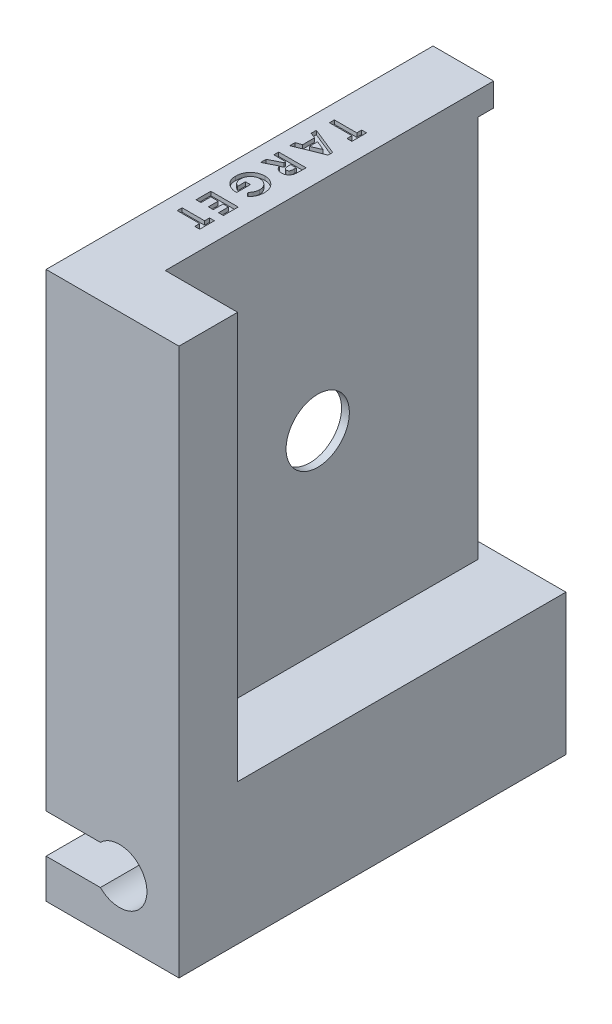
from build123d import *

# Parameters (mm, degrees)
ESQUISSE1_W              = 17
ESQUISSE1_H              = 85
BOSS_EXTRU_1_DEPTH       = 49.5
ESQUISSE2_W              = 1.8
ESQUISSE2_H              = 32.5
ENL_V_MAT_EXTRU_1_DEPTH  = 38.5
ESQUISSE3_W              = 17
ESQUISSE3_H              = 49
ENL_V_MAT_EXTRU_2_DEPTH  = 2
ESQUISSE4_R              = 16.25
ENL_V_MAT_EXTRU_3_DEPTH  = 18
ESQUISSE5_W              = 5.038353904
ESQUISSE5_H              = 10
ENL_V_MAT_EXTRU_4_DEPTH  = 18
ENL_V_MAT_EXTRU_5_DEPTH  = 50.5
ESQUISSE7_W              = 40
ESQUISSE7_H              = 49
ENL_V_MAT_EXTRU_7_DEPTH  = 13.25
BOSS_EXTRU_2_DEPTH       = 3
ESQUISSE10_W             = 40
ESQUISSE10_H             = 49
BOSS_EXTRU_3_DEPTH       = 1
ESQUISSE11_R             = 4.05
ENL_V_MAT_EXTRU_9_DEPTH  = 11.25
ESQUISSE12_W             = 17
ESQUISSE12_H             = 49.5
ENL_V_MAT_EXTRU_10_DEPTH = 15
ESQUISSE13_W             = 42
ESQUISSE13_H             = 3
ENL_V_MAT_EXTRU_11_DEPTH = 9.25
ENL_V_MAT_EXTRU_12_DEPTH = 0.5


with BuildPart() as part:
    # Esquisse1 → Boss.-Extru.1 (new body)
    with BuildSketch(Plane.XY):
        Rectangle(ESQUISSE1_W, ESQUISSE1_H)
    extrude(amount=BOSS_EXTRU_1_DEPTH)

    # Esquisse2 → Enlèv. mat.-Extru.1 (cut)
    with BuildSketch(Plane(origin=(0, 0, 0), x_dir=(-1, 0, 0), z_dir=(0, 0, -1))):
        with Locations((6.65, 0)):
            Rectangle(ESQUISSE2_W, ESQUISSE2_H)
    extrude(amount=-ENL_V_MAT_EXTRU_1_DEPTH, mode=Mode.SUBTRACT)

    # Esquisse3 → Enlèv. mat.-Extru.2 (cut)
    with BuildSketch(Plane(origin=(0, 0, 0), x_dir=(-1, 0, 0), z_dir=(0, 0, -1))):
        Rectangle(ESQUISSE3_W, ESQUISSE3_H)
    extrude(amount=-ENL_V_MAT_EXTRU_2_DEPTH, mode=Mode.SUBTRACT)

    # Esquisse4 → Enlèv. mat.-Extru.3 (cut, through all)
    with BuildSketch(Plane.ZY.offset(8.5)):
        with Locations((22.5, 0)):
            Circle(ESQUISSE4_R)
    extrude(amount=-ENL_V_MAT_EXTRU_3_DEPTH, mode=Mode.SUBTRACT)

    # Esquisse5 → Enlèv. mat.-Extru.4 (cut, through all)
    with BuildSketch(Plane.ZY.offset(8.5)):
        with Locations((4.519176952, 0)):
            Rectangle(ESQUISSE5_W, ESQUISSE5_H)
    extrude(amount=-ENL_V_MAT_EXTRU_4_DEPTH, mode=Mode.SUBTRACT)

    # Esquisse6 → Enlèv. mat.-Extru.5 (cut, through all)
    with BuildSketch(Plane(origin=(0, 0, 0), x_dir=(-1, 0, 0), z_dir=(0, 0, -1))):
        with BuildLine():
            Line((8.5, -32.5), (1.55, -32.5))
            ThreePointArc((1.55, -32.5), (-4.399489743, -35), (1.55, -37.5))
            Line((1.55, -37.5), (8.5, -37.5))
            Line((8.5, -37.5), (8.5, -32.5))
        make_face()
        with BuildLine():
            Line((8.5, 32.5), (8.5, 37.5))
            Line((8.5, 37.5), (1.55, 37.5))
            ThreePointArc((1.55, 37.5), (-4.399489743, 35), (1.55, 32.5))
            Line((1.55, 32.5), (8.5, 32.5))
        make_face()
    extrude(amount=-ENL_V_MAT_EXTRU_5_DEPTH, mode=Mode.SUBTRACT)

    # Esquisse7 → Enlèv. mat.-Extru.7 (cut)
    with BuildSketch(Plane(origin=(8.5, 0, 0), x_dir=(0, 0, -1), z_dir=(1, 0, 0))):
        with Locations((-22, 0)):
            Rectangle(ESQUISSE7_W, ESQUISSE7_H)
    extrude(amount=-ENL_V_MAT_EXTRU_7_DEPTH, mode=Mode.SUBTRACT)

    # Esquisse9 → Boss.-Extru.2 (add)
    with BuildSketch(Plane(origin=(-4.75, 0, 0), x_dir=(0, 0, -1), z_dir=(1, 0, 0))):
        with BuildLine():
            Line((-2, 5), (-2, 24.5))
            Line((-2, 24.5), (-42, 24.5))
            Line((-42, 24.5), (-42, -24.5))
            Line((-42, -24.5), (-2, -24.5))
            Line((-2, -24.5), (-2, -5))
            Line((-2, -5), (-7.038353904, -5))
            ThreePointArc((-7.038353904, -5), (-38.75, 0), (-7.038353904, 5))
            Line((-7.038353904, 5), (-2, 5))
        make_face()
    extrude(amount=BOSS_EXTRU_2_DEPTH)

    # Esquisse10 → Boss.-Extru.3 (add)
    with BuildSketch(Plane(origin=(-1.75, 0, 0), x_dir=(0, 0, -1), z_dir=(1, 0, 0))):
        with Locations((-22, 0)):
            Rectangle(ESQUISSE10_W, ESQUISSE10_H)
    extrude(amount=BOSS_EXTRU_3_DEPTH)

    # Esquisse11 → Enlèv. mat.-Extru.9 (cut, through all)
    with BuildSketch(Plane.ZY.offset(1.75)):
        with Locations((22.5, 0)):
            Circle(ESQUISSE11_R)
    extrude(amount=-ENL_V_MAT_EXTRU_9_DEPTH, mode=Mode.SUBTRACT)

    # Esquisse12 → Enlèv. mat.-Extru.10 (cut)
    with BuildSketch(Plane(origin=(0, 42.5, 0), x_dir=(1, 0, 0), z_dir=(0, 1, 0))):
        with Locations((0, -24.75)):
            Rectangle(ESQUISSE12_W, ESQUISSE12_H)
    extrude(amount=-ENL_V_MAT_EXTRU_10_DEPTH, mode=Mode.SUBTRACT)

    # Esquisse13 → Enlèv. mat.-Extru.11 (cut)
    with BuildSketch(Plane(origin=(8.5, 0, 0), x_dir=(0, 0, -1), z_dir=(1, 0, 0))):
        with Locations((-21, 26)):
            Rectangle(ESQUISSE13_W, ESQUISSE13_H)
    extrude(amount=-ENL_V_MAT_EXTRU_11_DEPTH, mode=Mode.SUBTRACT)

    # Esquisse14 → Enlèv. mat.-Extru.12 (cut)
    with BuildSketch(Plane(origin=(0, 27.5, 0), x_dir=(1, 0, 0), z_dir=(0, 1, 0))):
        Polygon((-3.125, -13.868589744), (-3.125, -15.753205128), (-3.753205128, -15.753205128), (-3.753205128, -15.125), (-6.625, -15.125), (-6.625, -14.496794872), (-3.753205128, -14.496794872), (-3.753205128, -13.868589744), align=None)
        Polygon((-3.125, -18.212880609), (-3.125, -18.795512821), (-6.625, -20.208974359), (-6.625, -19.538000801), (-5.907051282, -19.265965545), (-5.907051282, -17.741025641), (-6.625, -17.468990385), (-6.625, -16.798717949), align=None)
        Polygon((-4.063802083, -18.503846154), (-5.278846154, -17.979407051), (-5.278846154, -19.028285256), align=None, mode=Mode.SUBTRACT)
        with BuildLine():
            Line((-3.125, -21.613461538), (-3.125, -22.345432692))
            add(Edge.make_bspline(
                [(-3.125, -22.345432692), (-3.125171205, -22.39381584), (-3.12550048, -22.486870262), (-3.13071855, -22.621048417), (-3.137946771, -22.744313888), (-3.149112337, -22.857060277), (-3.163550741, -22.958841501), (-3.18106746, -23.04987313), (-3.200856587, -23.130208025), (-3.22511123, -23.200931168), (-3.253043139, -23.264579223), (-3.284570229, -23.323742033), (-3.320883804, -23.379462471), (-3.360512458, -23.432763276), (-3.404875546, -23.482693055), (-3.453613558, -23.529113465), (-3.506375192, -23.572621393), (-3.562843178, -23.613274416), (-3.622938688, -23.649450963), (-3.685808413, -23.681501598), (-3.751622243, -23.707834205), (-3.820003407, -23.729760006), (-3.891034135, -23.746641538), (-3.964668311, -23.758103474), (-4.040937235, -23.766578526), (-4.092756923, -23.767061382), (-4.119190705, -23.767307692)],
                knots=[0, 0, 0, 0, 0.000145139, 0.000279143, 0.000402781, 0.00051552, 0.000618938, 0.000711065, 0.000793539, 0.000866929, 0.000935057, 0.00100187, 0.001067798, 0.001134404, 0.001200955, 0.001267901, 0.001336126, 0.001405975, 0.001476437, 0.001546359, 0.001617446, 0.001688844, 0.001761629, 0.001836205, 0.001912318, 0.001991573, 0.001991573, 0.001991573, 0.001991573], degree=3))
            add(Edge.make_bspline(
                [(-4.119190705, -23.767307692), (-4.146780964, -23.76666373), (-4.200880432, -23.765401038), (-4.280348139, -23.758599489), (-4.356377283, -23.746168395), (-4.428745259, -23.727339694), (-4.498352771, -23.705698549), (-4.563915518, -23.676921376), (-4.626387014, -23.644443493), (-4.684883576, -23.60587046), (-4.740704531, -23.56353844), (-4.791711169, -23.514307192), (-4.840644906, -23.461366144), (-4.884440697, -23.401739286), (-4.926059855, -23.338055027), (-4.963777897, -23.269048027), (-4.998542965, -23.195168648), (-5.017930369, -23.143227787), (-5.027844551, -23.116666667)],
                knots=[0, 0, 0, 0, 8.278e-05, 0.000162316, 0.000239082, 0.000313563, 0.00038651, 0.000457489, 0.000528056, 0.000597481, 0.00066746, 0.000737887, 0.000809857, 0.000883475, 0.000959513, 0.001037964, 0.001119203, 0.001204224, 0.001204224, 0.001204224, 0.001204224], degree=3))
            Line((-5.027844551, -23.116666667), (-6.625, -23.924358974))
            Line((-6.625, -23.924358974), (-6.625, -23.226041667))
            Line((-6.625, -23.226041667), (-5.099358974, -22.454807692))
            Line((-5.099358974, -22.454807692), (-5.099358974, -22.241666667))
            Line((-5.099358974, -22.241666667), (-6.625, -22.241666667))
            Line((-6.625, -22.241666667), (-6.625, -21.613461538))
            Line((-6.625, -21.613461538), (-3.125, -21.613461538))
        make_face()
        with BuildLine():
            Line((-4.471153846, -22.241666667), (-4.471153846, -22.486358173))
            add(Edge.make_bspline(
                [(-4.471153846, -22.486358173), (-4.470816922, -22.516273749), (-4.470171784, -22.573555647), (-4.46717926, -22.655934466), (-4.459969123, -22.730754344), (-4.450858432, -22.798335434), (-4.440341805, -22.859021498), (-4.425260708, -22.912259442), (-4.409130369, -22.95890703), (-4.388988461, -22.998294497), (-4.36648554, -23.032083571), (-4.339793749, -23.060405717), (-4.310554308, -23.085356509), (-4.276926871, -23.104928126), (-4.240289149, -23.120740731), (-4.199951838, -23.130547198), (-4.156645292, -23.138327701), (-4.126476463, -23.138837352), (-4.110777244, -23.139102564)],
                knots=[0, 0, 0, 0, 8.9755e-05, 0.000171861, 0.000247208, 0.00031513, 0.000376461, 0.000431743, 0.000480981, 0.000524253, 0.000564118, 0.000602321, 0.000640653, 0.00067901, 0.000718597, 0.000759921, 0.000803261, 0.000850283, 0.000850283, 0.000850283, 0.000850283], degree=3))
            add(Edge.make_bspline(
                [(-4.110777244, -23.139102564), (-4.09222809, -23.138390035), (-4.055791716, -23.136990404), (-4.003336833, -23.123100941), (-3.954783461, -23.100993643), (-3.910364563, -23.070684318), (-3.87138373, -23.03253717), (-3.837301568, -22.98883429), (-3.809723178, -22.938930964), (-3.792060609, -22.892395299), (-3.781204052, -22.849763229), (-3.7734973, -22.811414204), (-3.767521787, -22.766885147), (-3.76173705, -22.716424527), (-3.757755271, -22.659815341), (-3.754937957, -22.597162138), (-3.753768959, -22.528429509), (-3.753398483, -22.480515581), (-3.753205128, -22.455508814)],
                knots=[0, 0, 0, 0, 5.5548e-05, 0.000109114, 0.000161511, 0.00021499, 0.000269533, 0.000324507, 0.000380689, 0.000439937, 0.000473268, 0.000512593, 0.000557212, 0.000608004, 0.00066495, 0.000727413, 0.000796137, 0.000871161, 0.000871161, 0.000871161, 0.000871161], degree=3))
            Line((-3.753205128, -22.455508814), (-3.753205128, -22.241666667))
            Line((-3.753205128, -22.241666667), (-4.471153846, -22.241666667))
        make_face(mode=Mode.SUBTRACT)
        with BuildLine():
            Line((-3.681690705, -28.536478365), (-4.13671875, -28.061117788))
            add(Edge.make_bspline(
                [(-4.13671875, -28.061117788), (-4.09903853, -28.023482662), (-4.025103718, -27.949636331), (-3.928872479, -27.828869894), (-3.847056902, -27.703792517), (-3.779782411, -27.57399252), (-3.727598467, -27.43928909), (-3.690269622, -27.299948057), (-3.668129252, -27.155742728), (-3.665029676, -27.058122158), (-3.663461538, -27.008733974)],
                knots=[0, 0, 0, 0, 0.000159665, 0.000313289, 0.000462251, 0.000607437, 0.000751051, 0.00089476, 0.001039431, 0.001187569, 0.001187569, 0.001187569, 0.001187569], degree=3))
            add(Edge.make_bspline(
                [(-3.663461538, -27.008733974), (-3.664560387, -26.965915975), (-3.666718071, -26.881839081), (-3.683101589, -26.758295399), (-3.710474184, -26.640244847), (-3.748378242, -26.527115607), (-3.797761759, -26.419650154), (-3.857508307, -26.317195413), (-3.929112634, -26.220922185), (-4.009688005, -26.13041886), (-4.098325189, -26.048193311), (-4.192380208, -25.975412329), (-4.291645212, -25.91427569), (-4.395555322, -25.86379517), (-4.504315009, -25.825438339), (-4.61778091, -25.798042883), (-4.735640617, -25.780656994), (-4.816045081, -25.778603978), (-4.856770833, -25.777564103)],
                knots=[0, 0, 0, 0, 0.000128428, 0.000252179, 0.0003731, 0.000491496, 0.000609462, 0.000727305, 0.00084664, 0.000968796, 0.001090341, 0.001208839, 0.001325001, 0.001439458, 0.001554771, 0.001670234, 0.001789219, 0.001911343, 0.001911343, 0.001911343, 0.001911343], degree=3))
            add(Edge.make_bspline(
                [(-4.856770833, -25.777564103), (-4.898903584, -25.778540798), (-4.981910869, -25.780465022), (-5.10377296, -25.798722668), (-5.220760518, -25.827343268), (-5.333009908, -25.867408437), (-5.440201993, -25.919638348), (-5.54215585, -25.98394489), (-5.639323402, -26.059377565), (-5.730364664, -26.145280704), (-5.814255254, -26.238763458), (-5.886671554, -26.33997781), (-5.948871732, -26.445766043), (-5.998875662, -26.557842397), (-6.038088993, -26.67477728), (-6.066280242, -26.797311552), (-6.083416762, -26.925045979), (-6.085487537, -27.01218627), (-6.086538462, -27.056410256)],
                knots=[0, 0, 0, 0, 0.000126327, 0.000248881, 0.000368764, 0.000487189, 0.000605718, 0.000725743, 0.000848175, 0.000974163, 0.001100802, 0.001224363, 0.001346898, 0.001468346, 0.001591841, 0.001716335, 0.001845044, 0.001977675, 0.001977675, 0.001977675, 0.001977675], degree=3))
            add(Edge.make_bspline(
                [(-6.086538462, -27.056410256), (-6.08627865, -27.08517687), (-6.085768583, -27.141652133), (-6.077500448, -27.224493497), (-6.065662121, -27.303828897), (-6.050052702, -27.379996611), (-6.027667928, -27.452326066), (-6.002336962, -27.521798872), (-5.97095299, -27.587502497), (-5.935337704, -27.650009553), (-5.894318794, -27.709376712), (-5.848080736, -27.765412189), (-5.796202585, -27.81830461), (-5.739678827, -27.868965315), (-5.676858535, -27.915674286), (-5.609298956, -27.960083728), (-5.536251589, -28.001610752), (-5.48467238, -28.026150573), (-5.458333333, -28.038681891)],
                knots=[0, 0, 0, 0, 8.6264e-05, 0.000169355, 0.000249473, 0.000326892, 0.000402308, 0.000476408, 0.000548542, 0.000620461, 0.00069203, 0.000764744, 0.000838124, 0.000914108, 0.000992213, 0.00107272, 0.001156553, 0.001244036, 0.001244036, 0.001244036, 0.001244036], degree=3))
            Line((-5.458333333, -28.038681891), (-5.458333333, -27.033974359))
            Line((-5.458333333, -27.033974359), (-4.830128205, -27.033974359))
            Line((-4.830128205, -27.033974359), (-4.830128205, -28.779066506))
            Line((-4.830128205, -28.779066506), (-4.979467147, -28.783974359))
            add(Edge.make_bspline(
                [(-4.979467147, -28.783974359), (-5.017821177, -28.783343736), (-5.09446079, -28.782083617), (-5.208564118, -28.770567445), (-5.321154101, -28.751491081), (-5.432117658, -28.725411866), (-5.541999105, -28.692728012), (-5.649746234, -28.651045868), (-5.756089752, -28.602236332), (-5.860577781, -28.547548709), (-5.960836885, -28.486095556), (-6.055769022, -28.419932213), (-6.145209884, -28.350001884), (-6.227913337, -28.274783614), (-6.304574125, -28.195448674), (-6.374897326, -28.111840892), (-6.438942441, -28.023664553), (-6.497250505, -27.931386762), (-6.548354083, -27.834481907), (-6.592807417, -27.733482771), (-6.630560694, -27.62854185), (-6.661510169, -27.51938821), (-6.685390151, -27.406236639), (-6.701764686, -27.289084712), (-6.712891367, -27.167868089), (-6.714118718, -27.085649417), (-6.71474359, -27.043790064)],
                knots=[0, 0, 0, 0, 0.000115037, 0.00022987, 0.000343635, 0.000457409, 0.00057164, 0.000687266, 0.000803665, 0.000922527, 0.001040849, 0.001156185, 0.001269517, 0.001381198, 0.001491277, 0.001600258, 0.001708662, 0.001817986, 0.001927444, 0.002037003, 0.002148778, 0.002261746, 0.002377116, 0.002495407, 0.002616457, 0.002742007, 0.002742007, 0.002742007, 0.002742007], degree=3))
            add(Edge.make_bspline(
                [(-6.71474359, -27.043790064), (-6.714120749, -26.999130015), (-6.712886094, -26.910600478), (-6.701533704, -26.779909962), (-6.682340112, -26.652857092), (-6.656635274, -26.529640446), (-6.623482514, -26.409715171), (-6.583277032, -26.293531108), (-6.534073969, -26.181509422), (-6.479265711, -26.072948813), (-6.416509657, -25.969203767), (-6.348152794, -25.870220713), (-6.272714392, -25.77735012), (-6.190965313, -25.69020312), (-6.103616331, -25.608160424), (-6.0094927, -25.53202491), (-5.909503236, -25.461111812), (-5.80298339, -25.397157854), (-5.692841277, -25.339073942), (-5.579725216, -25.288485297), (-5.464512098, -25.245600061), (-5.347176669, -25.210450721), (-5.227721731, -25.183111867), (-5.10621978, -25.163269113), (-4.982480577, -25.152129362), (-4.899326483, -25.150286537), (-4.857471955, -25.149358974)],
                knots=[0, 0, 0, 0, 0.00013396, 0.000265549, 0.000393163, 0.000519258, 0.00064292, 0.000766205, 0.000887728, 0.001009703, 0.001130786, 0.001251177, 0.001370312, 0.001489363, 0.001609404, 0.001729525, 0.001852272, 0.001976843, 0.002101975, 0.002225629, 0.002348309, 0.002470532, 0.002592819, 0.002715691, 0.002839598, 0.002965169, 0.002965169, 0.002965169, 0.002965169], degree=3))
            add(Edge.make_bspline(
                [(-4.857471955, -25.149358974), (-4.800372853, -25.150599241), (-4.687619055, -25.153048399), (-4.521531995, -25.175731325), (-4.360859337, -25.211090625), (-4.206186239, -25.261834782), (-4.057299637, -25.326951518), (-3.913850014, -25.405518396), (-3.775989843, -25.499242059), (-3.69063525, -25.571790611), (-3.647335737, -25.60859375)],
                knots=[0, 0, 0, 0, 0.000171217, 0.000338103, 0.00050191, 0.000664207, 0.000825594, 0.000988761, 0.001154253, 0.001324641, 0.001324641, 0.001324641, 0.001324641], degree=3))
            add(Edge.make_bspline(
                [(-3.647335737, -25.60859375), (-3.622285656, -25.63144446), (-3.572561623, -25.676802775), (-3.503469067, -25.749307959), (-3.438519508, -25.823651894), (-3.379090161, -25.900864257), (-3.323880089, -25.980539156), (-3.273924249, -26.062905909), (-3.22763202, -26.14753244), (-3.187367259, -26.235078733), (-3.151266542, -26.325086471), (-3.120720259, -26.417954284), (-3.093663514, -26.512986611), (-3.073080269, -26.611024967), (-3.055940114, -26.71107893), (-3.044451885, -26.813858717), (-3.036031831, -26.919084247), (-3.035516928, -26.990253503), (-3.03525641, -27.026262019)],
                knots=[0, 0, 0, 0, 0.000101692, 0.000201856, 0.000300264, 0.00039773, 0.000493998, 0.000590915, 0.0006866, 0.000783215, 0.00087982, 0.000977374, 0.001076379, 0.001176078, 0.001277741, 0.001380796, 0.001486247, 0.00159424, 0.00159424, 0.00159424, 0.00159424], degree=3))
            add(Edge.make_bspline(
                [(-3.03525641, -27.026262019), (-3.035836893, -27.063902609), (-3.03699184, -27.138793561), (-3.044983322, -27.250144006), (-3.057312294, -27.359947161), (-3.075806457, -27.467740305), (-3.098613609, -27.573885194), (-3.127835215, -27.677832395), (-3.161036224, -27.780260036), (-3.187506521, -27.846940042), (-3.200721154, -27.880228365)],
                knots=[0, 0, 0, 0, 0.000112915, 0.00022466, 0.000334761, 0.000444262, 0.00055263, 0.000660304, 0.000768058, 0.000875478, 0.000875478, 0.000875478, 0.000875478], degree=3))
            add(Edge.make_bspline(
                [(-3.200721154, -27.880228365), (-3.212933853, -27.908236371), (-3.237774146, -27.965203881), (-3.283220626, -28.048084586), (-3.333603265, -28.131167791), (-3.390764169, -28.213556986), (-3.454596422, -28.295126634), (-3.524091803, -28.376728407), (-3.600060667, -28.457529287), (-3.654128304, -28.50982119), (-3.681690705, -28.536478365)],
                knots=[0, 0, 0, 0, 9.1622e-05, 0.000186356, 0.000283274, 0.000383045, 0.000486967, 0.00059389, 0.000704501, 0.000819523, 0.000819523, 0.000819523, 0.000819523], degree=3))
        make_face()
        Polygon((-3.125, -30.300641026), (-3.125, -32.18525641), (-3.753205128, -32.18525641), (-3.753205128, -30.928846154), (-4.426282051, -30.928846154), (-4.426282051, -32.18525641), (-5.054487179, -32.18525641), (-5.054487179, -30.928846154), (-5.996794872, -30.928846154), (-5.996794872, -32.18525641), (-6.625, -32.18525641), (-6.625, -30.300641026), align=None)
        Polygon((-3.125, -33.342948718), (-3.125, -35.227564103), (-3.753205128, -35.227564103), (-3.753205128, -34.599358974), (-6.625, -34.599358974), (-6.625, -33.971153846), (-3.753205128, -33.971153846), (-3.753205128, -33.342948718), align=None)
    extrude(amount=-ENL_V_MAT_EXTRU_12_DEPTH, mode=Mode.SUBTRACT)


solid = part.part
